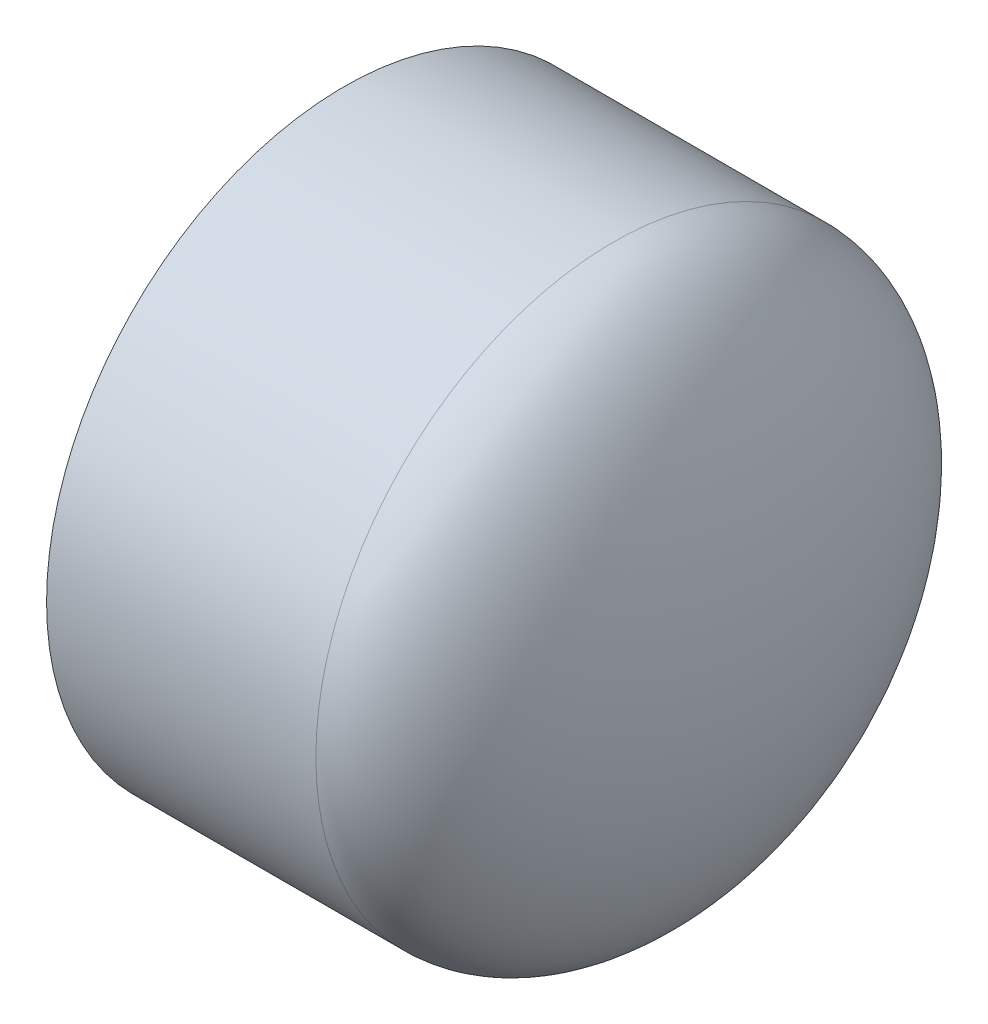
from build123d import *


with BuildPart() as part:
    # Sketch1 → Revolve1 (revolve)
    with BuildSketch(Plane.XY):
        with BuildLine():
            Line((-74.93, -54.737), (-25.4, -54.737))
            add(Edge.make_bspline(
                [(-25.4, -54.737), (0, -54.737), (0, 0)],
                knots=[3.141592654, 3.141592654, 3.141592654, 4.71238898, 4.71238898, 4.71238898], degree=2, weights=[1, 0.707106781, 1]))
            Line((0, 0), (-10.3886, 0))
            add(Edge.make_bspline(
                [(-25.4, -44.3484), (-10.3886, -44.3484), (-10.3886, 0)],
                knots=[0, 0, 0, 1.570796327, 1.570796327, 1.570796327], degree=2, weights=[1, 0.707106781, 1]))
            Line((-25.4, -44.3484), (-74.93, -44.6532))
            Line((-74.93, -44.6532), (-74.93, -54.737))
        make_face()
    revolve(axis=Axis((-74.93, 0, 0), (1, 0, 0)))


solid = part.part
